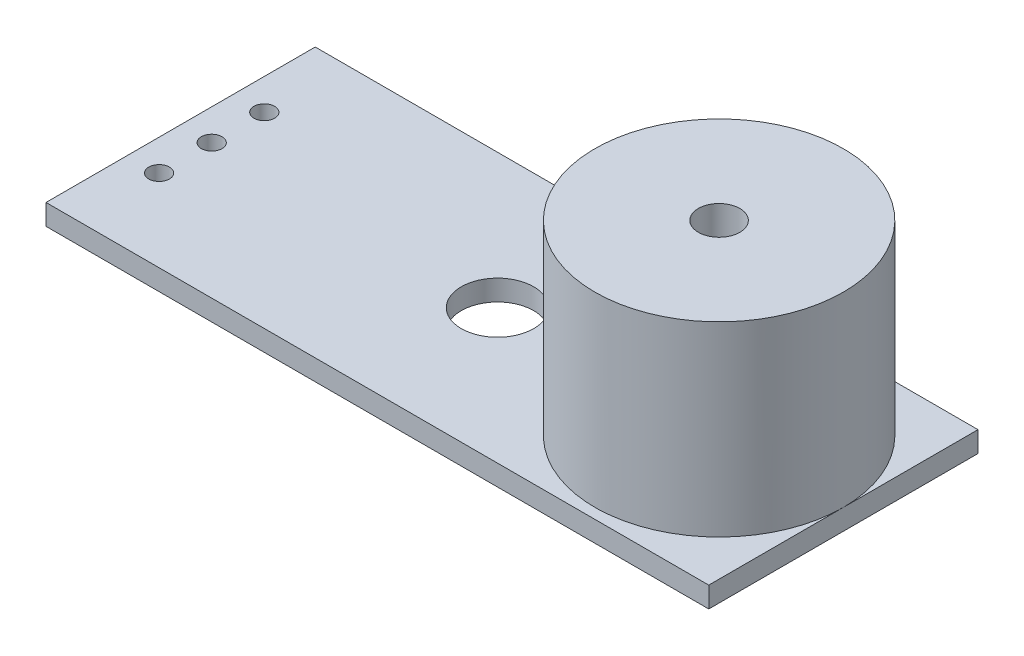
from build123d import *

# Parameters (mm, degrees)
SKETCH_1_W          = 32
SKETCH_1_H          = 13
EXTRUDE_1_DEPTH     = 1
SKETCH_2_R          = 1.75
CUT_EXTRUDE_1_DEPTH = 2
EXTRUDE_START       = -1
SKETCH_4_R          = 6
EXTRUDE_2_DEPTH     = 10
SKETCH_5_R          = 0.5
CUT_EXTRUDE_2_DEPTH = 2
SKETCH_6_R          = 1
CUT_EXTRUDE_3_DEPTH = 2


with BuildPart() as part:
    # 草图1 → 凸台-拉伸1 (new body)
    with BuildSketch(Plane(origin=(0, 0, 0), x_dir=(1, 0, 0), z_dir=(0, 1, 0))):
        Rectangle(SKETCH_1_W, SKETCH_1_H)
    extrude(amount=EXTRUDE_1_DEPTH)

    # 草图2 → 切除-拉伸1 (cut, through all)
    with BuildSketch(Plane(origin=(0, 1, 0), x_dir=(1, 0, 0), z_dir=(0, 1, 0))):
        with Locations((-0.7, 0)):
            Circle(SKETCH_2_R)
    extrude(amount=-CUT_EXTRUDE_1_DEPTH, mode=Mode.SUBTRACT)

    # 草图4 → 凸台-拉伸2 (add)
    with BuildSketch(Plane(origin=(0, 1, 0), x_dir=(1, 0, 0), z_dir=(0, 1, 0)).offset(EXTRUDE_START)):
        with Locations((10, 0)):
            Circle(SKETCH_4_R)
    extrude(amount=EXTRUDE_2_DEPTH)

    # 草图5 → 切除-拉伸2 (cut, through all)
    with BuildSketch(Plane(origin=(0, 1, 0), x_dir=(1, 0, 0), z_dir=(0, 1, 0))):
        with Locations((-14.5, 2.54)):
            Circle(SKETCH_5_R)
        with Locations((-14.5, 0)):
            Circle(SKETCH_5_R)
        with Locations((-14.5, -2.54)):
            Circle(SKETCH_5_R)
    extrude(amount=-CUT_EXTRUDE_2_DEPTH, mode=Mode.SUBTRACT)

    # 草图6 → 切除-拉伸3 (cut)
    with BuildSketch(Plane(origin=(0, 10, 0), x_dir=(1, 0, 0), z_dir=(0, 1, 0))):
        with Locations((10, 0)):
            Circle(SKETCH_6_R)
    extrude(amount=-CUT_EXTRUDE_3_DEPTH, mode=Mode.SUBTRACT)


solid = part.part
